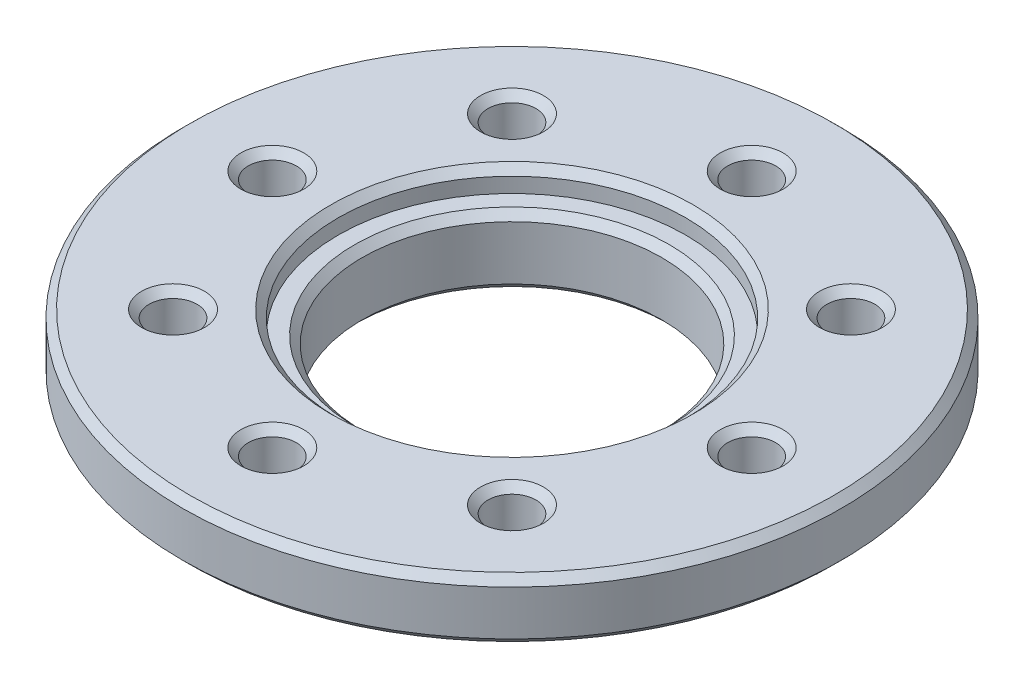
from build123d import *

# Parameters (mm, degrees)
SKETCH1_W                               = 11
SKETCH1_H                               = 2
SKETCH2_R                               = 6.25
BOSS_EXTRUDE1_DEPTH                     = 1.05
F_1_6_1_6_DIAMETER_HOLE1_D              = 1.6
F_1_6_1_6_DIAMETER_HOLE1_DEPTH          = 3.05
CBORE_FOR_M8_HEX_HEAD_BOLT1_D           = 10
CBORE_FOR_M8_HEX_HEAD_BOLT1_DEPTH       = 3.05
CBORE_FOR_M8_HEX_HEAD_BOLT1_CBORE_D     = 11.6
CBORE_FOR_M8_HEX_HEAD_BOLT1_CBORE_DEPTH = 0.75
CHAMFER1_SIZE                           = 0.25


with BuildPart() as part:
    # Sketch1 → Revolve1 (revolve)
    with BuildSketch(Plane.XY):
        with Locations((5.5, -1)):
            Rectangle(SKETCH1_W, SKETCH1_H)
    revolve(axis=Axis((0, 0, 0), (0, -1, 0)))

    # Sketch2 → Boss-Extrude1 (add)
    with BuildSketch(Plane.XZ.offset(2)):
        Circle(SKETCH2_R)
    extrude(amount=BOSS_EXTRUDE1_DEPTH)

    # Ø1.6 (1.6) Diameter Hole1
    with Locations(Plane(origin=(0, 0, 0), x_dir=(1, 0, 0), z_dir=(0, 1, 0))):
        with Locations((0, 8), (5.656854249, 5.656854249), (8, 0), (5.656854249, -5.656854249), (0, -8), (-5.656854249, -5.656854249), (-8, 0), (-5.656854249, 5.656854249)):
            Hole(F_1_6_1_6_DIAMETER_HOLE1_D / 2, depth=F_1_6_1_6_DIAMETER_HOLE1_DEPTH)

    # CBORE for M8 Hex Head Bolt1
    with Locations(Plane(origin=(0, 0, 0), x_dir=(1, 0, 0), z_dir=(0, 1, 0))):
        with Locations((0, 0)):
            CounterBoreHole(CBORE_FOR_M8_HEX_HEAD_BOLT1_D / 2, CBORE_FOR_M8_HEX_HEAD_BOLT1_CBORE_D / 2, CBORE_FOR_M8_HEX_HEAD_BOLT1_CBORE_DEPTH, depth=CBORE_FOR_M8_HEX_HEAD_BOLT1_DEPTH)

    # Chamfer1
    chamfer1_edges = [part.edges().sort_by_distance(p)[0] for p in [
        (-4.856854249, 0, -5.656854249),
        (-7.2, 0, 0),
        (-4.856854249, 0, 5.656854249),
        (-11, -2, 0),
        (0.8, 0, 8),
        (6.456854249, 0, 5.656854249),
        (-11, 0, 0),
        (8.8, 0, 0),
        (6.456854249, 0, -5.656854249),
        (0.8, 0, -8),
        (-5.8, 0, 0),
        (5, -3.05, 0),
        (5, -0.75, 0),
        (-6.25, -3.05, 0),
    ]]
    chamfer(chamfer1_edges, length=CHAMFER1_SIZE)


solid = part.part
